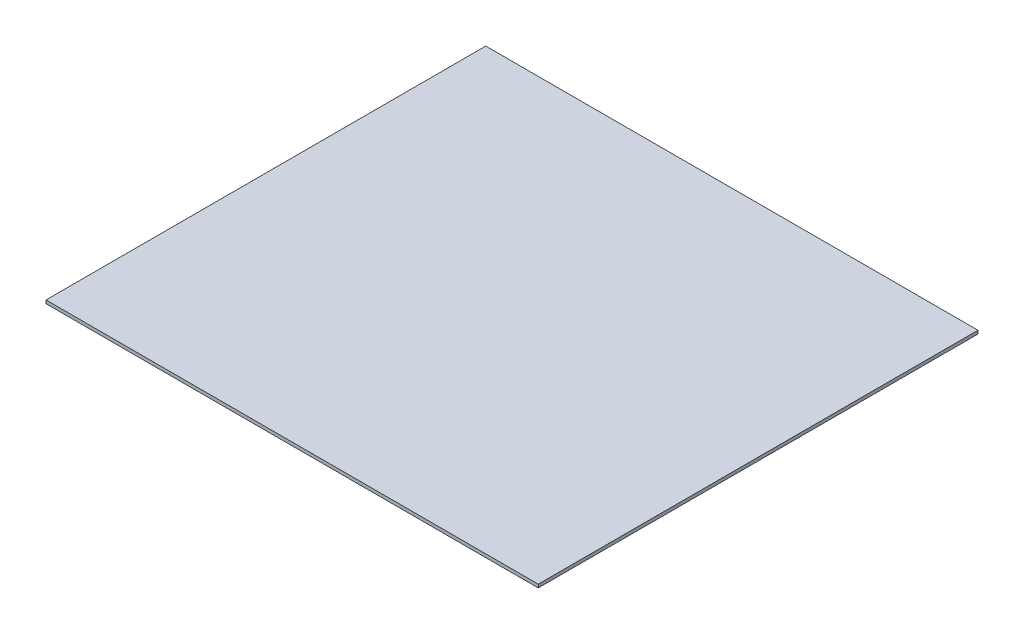
from build123d import *

# Parameters (mm, degrees)
SKETCH1_W           = 750
SKETCH1_H           = 670
BOSS_EXTRUDE1_DEPTH = 5


with BuildPart() as part:
    # Sketch1 → Boss-Extrude1 (new body)
    with BuildSketch(Plane(origin=(0, 0, 0), x_dir=(1, 0, 0), z_dir=(0, 1, 0))):
        with Locations((-375, 335)):
            Rectangle(SKETCH1_W, SKETCH1_H)
    extrude(amount=BOSS_EXTRUDE1_DEPTH)


solid = part.part
